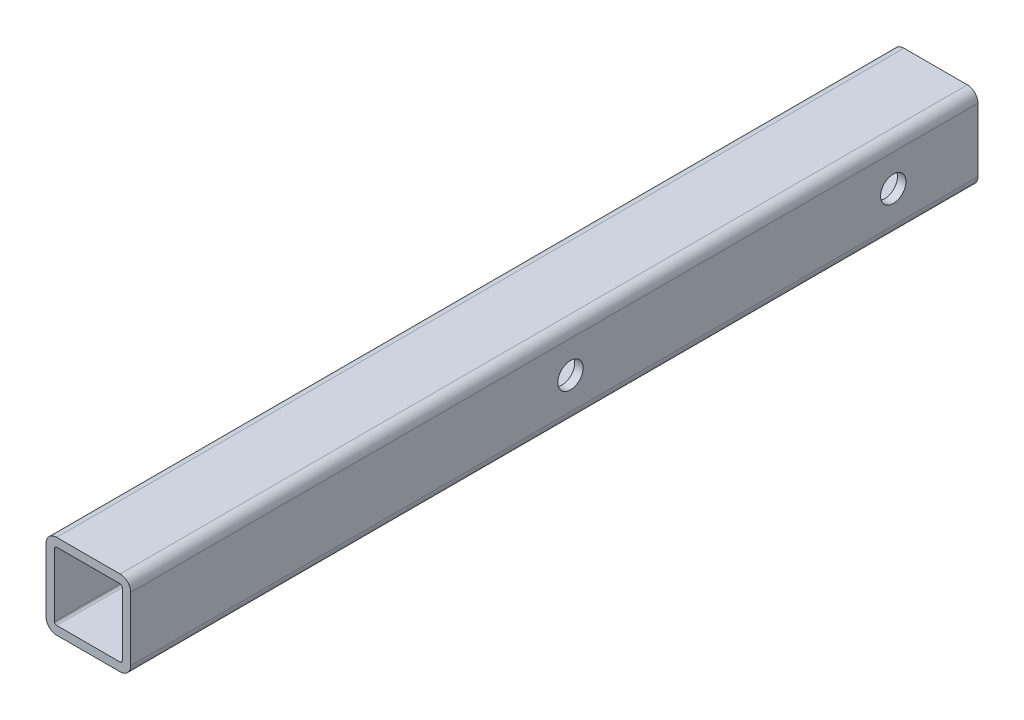
from build123d import *

# Parameters (mm, degrees)
EXTRUDE_THIN1_DEPTH   = 100
IZIM1_R               = 3
KES_EKSTR_ZYON1_DEPTH = 20.32


with BuildPart() as part:
    # Sketch1 → Extrude-Thin1 (new body, symmetric)
    with BuildSketch(Plane.XY):
        with BuildLine():
            Line((-10, -7.5), (-10, 7.5))
            ThreePointArc((-10, 7.5), (-9.267766953, 9.267766953), (-7.5, 10))
            Line((-7.5, 10), (7.5, 10))
            ThreePointArc((7.5, 10), (9.267766953, 9.267766953), (10, 7.5))
            Line((10, 7.5), (10, -7.5))
            ThreePointArc((10, -7.5), (9.267766953, -9.267766953), (7.5, -10))
            Line((7.5, -10), (-7.5, -10))
            ThreePointArc((-7.5, -10), (-9.267766953, -9.267766953), (-10, -7.5))
        make_face()
        with BuildLine():
            Line((-8, -7.5), (-8, 7.5))
            ThreePointArc((-8, 7.5), (-7.853553391, 7.853553391), (-7.5, 8))
            Line((-7.5, 8), (7.5, 8))
            ThreePointArc((7.5, 8), (7.853553391, 7.853553391), (8, 7.5))
            Line((8, 7.5), (8, -7.5))
            ThreePointArc((8, -7.5), (7.853553391, -7.853553391), (7.5, -8))
            Line((7.5, -8), (-7.5, -8))
            ThreePointArc((-7.5, -8), (-7.853553391, -7.853553391), (-8, -7.5))
        make_face(mode=Mode.SUBTRACT)
    extrude(amount=EXTRUDE_THIN1_DEPTH, both=True)

    # Çizim1 → Kes-Ekstrüzyon1 (cut)
    with BuildSketch(Plane(origin=(10, 0, 0), x_dir=(0, 0, -1), z_dir=(1, 0, 0))):
        with Locations((80, 0)):
            Circle(IZIM1_R)
        with Locations((3.8, 0)):
            Circle(IZIM1_R)
    extrude(amount=-KES_EKSTR_ZYON1_DEPTH, mode=Mode.SUBTRACT)


solid = part.part
